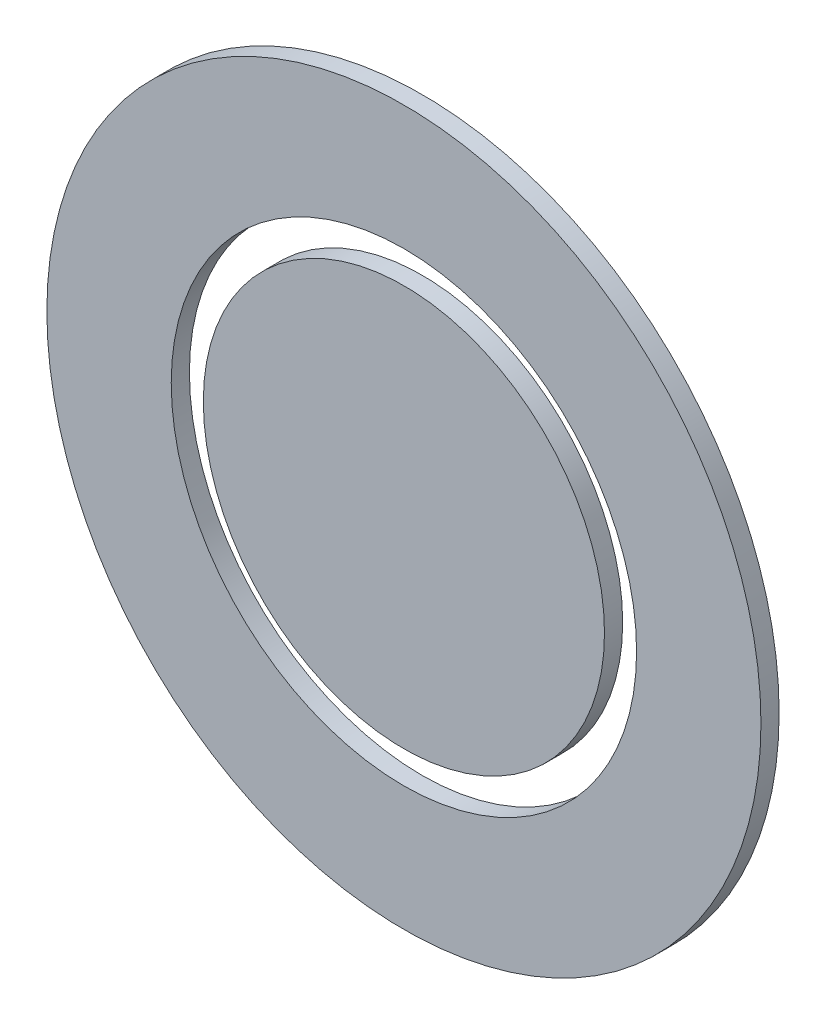
from build123d import *

# Parameters (mm, degrees)
SKETCH1_R           = 75
BOSS_EXTRUDE1_DEPTH = 6.8
SKETCH1_4_R         = 133.5
SKETCH1_4_R_2       = 87
BOSS_EXTRUDE2_DEPTH = 6.8


with BuildPart() as part:
    # Sketch1 → Boss-Extrude1 (new body)
    with BuildSketch(Plane.XY):
        Circle(SKETCH1_R)
    extrude(amount=BOSS_EXTRUDE1_DEPTH)


with BuildPart() as body_2:
    # Sketch1_4 → Boss-Extrude2 (new body)
    with BuildSketch(Plane.XY):
        Circle(SKETCH1_4_R)
        Circle(SKETCH1_4_R_2, mode=Mode.SUBTRACT)
    extrude(amount=BOSS_EXTRUDE2_DEPTH)


solid = Compound([part.part, body_2.part])
